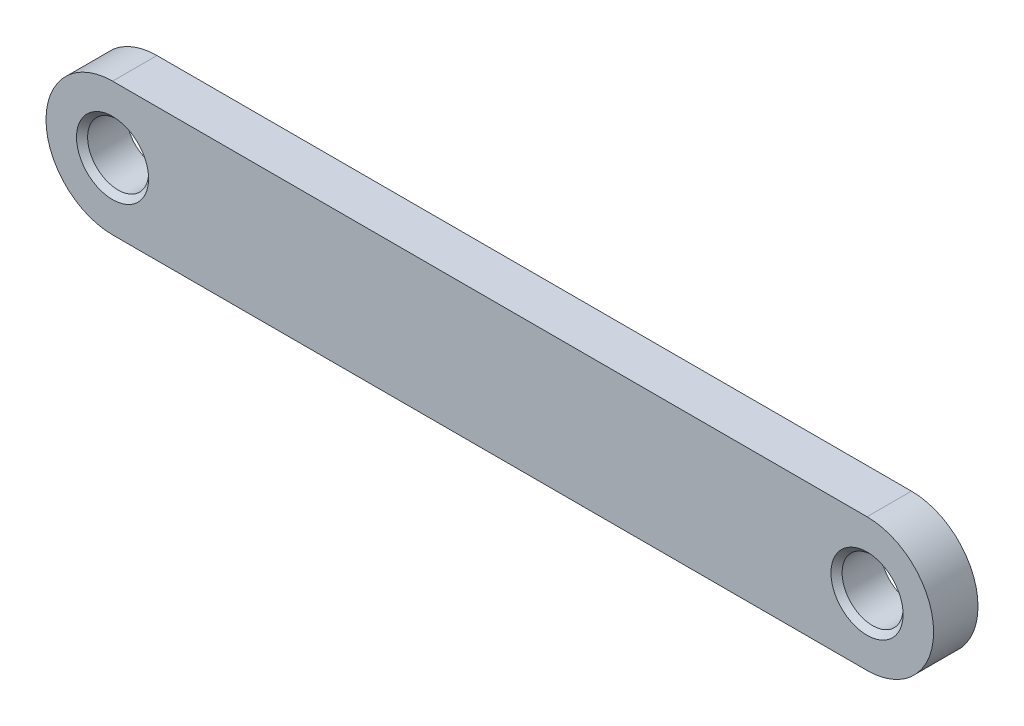
from build123d import *

# Parameters (mm, degrees)
SKETCH1_R           = 1.375
BOSS_EXTRUDE1_DEPTH = 2
CHAMFER1_SIZE       = 0.25


with BuildPart() as part:
    # Sketch1 → Boss-Extrude1 (new body)
    with BuildSketch(Plane.XY):
        with BuildLine():
            Line((44.5, -47.65), (10.5, -47.65))
            ThreePointArc((10.5, -47.65), (7.5, -50.65), (10.5, -53.65))
            Line((10.5, -53.65), (44.5, -53.65))
            ThreePointArc((44.5, -53.65), (47.5, -50.65), (44.5, -47.65))
        make_face()
        with Locations((10.5, -50.65)):
            Circle(SKETCH1_R, mode=Mode.SUBTRACT)
        with Locations((44.5, -50.65)):
            Circle(SKETCH1_R, mode=Mode.SUBTRACT)
    extrude(amount=BOSS_EXTRUDE1_DEPTH)

    # Chamfer1
    chamfer1_edges = [part.edges().sort_by_distance(p)[0] for p in [
        (9.125, -50.65, 2),
        (43.125, -50.65, 2),
    ]]
    chamfer(chamfer1_edges, length=CHAMFER1_SIZE)


solid = part.part
